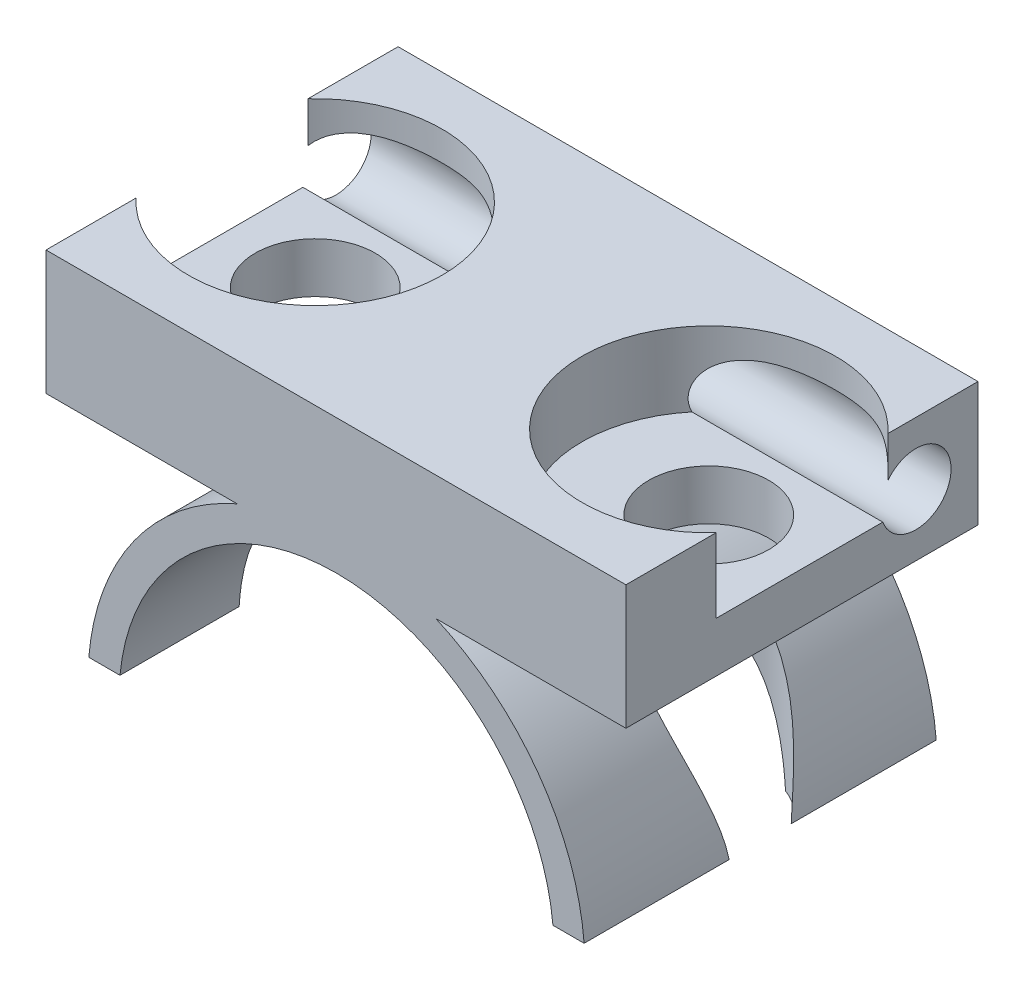
from build123d import *

# Parameters (mm, degrees)
SALIENTE_EXTRUIR1_DEPTH                              = 17
TALADRO_DE_MARGEN_PARA_M31_D                         = 3.4
REFRENTADO_PARA_PERNO_CON_CABEZA_HEXAGON_D           = 5.8
REFRENTADO_PARA_PERNO_CON_CABEZA_HEXAGON_CBORE_D     = 12.24
REFRENTADO_PARA_PERNO_CON_CABEZA_HEXAGON_CBORE_DEPTH = 3.58


with BuildPart() as part:
    # Croquis1 → Saliente-Extruir1 (new body)
    with BuildSketch(Plane.XY):
        with BuildLine():
            Line((13.975508884, 11), (13.975508884, 17))
            Line((13.975508884, 17), (-14.024491116, 17))
            Line((-14.024491116, 17), (-14.024491116, 11))
            Line((-14.024491116, 11), (-4.795831523, 11))
            ThreePointArc((-4.795831523, 11), (-9.755762498, 6.987495838), (-11.958260743, 1))
            Line((-11.958260743, 1), (-10.45227248, 1))
            ThreePointArc((-10.45227248, 1), (0, 10.5), (10.45227248, 1))
            Line((10.45227248, 1), (11.958260743, 1))
            ThreePointArc((11.958260743, 1), (9.755762498, 6.987495838), (4.795831523, 11))
            Line((4.795831523, 11), (13.975508884, 11))
        make_face()
    extrude(amount=SALIENTE_EXTRUIR1_DEPTH)

    # Taladro de margen para M31 (through all)
    with Locations(Plane(origin=(13.975508884, 0, 0), x_dir=(0, 0, -1), z_dir=(1, 0, 0))):
        with Locations((-3, 14)):
            Hole(TALADRO_DE_MARGEN_PARA_M31_D / 2)

    # Refrentado para perno con cabeza hexagonal de M51 (through all)
    with Locations(Plane(origin=(0, 17, 0), x_dir=(1, 0, 0), z_dir=(0, 1, 0))):
        with Locations((9.475508884, -8.5), (-9.524491116, -8.5)):
            CounterBoreHole(REFRENTADO_PARA_PERNO_CON_CABEZA_HEXAGON_D / 2, REFRENTADO_PARA_PERNO_CON_CABEZA_HEXAGON_CBORE_D / 2, REFRENTADO_PARA_PERNO_CON_CABEZA_HEXAGON_CBORE_DEPTH)


solid = part.part
